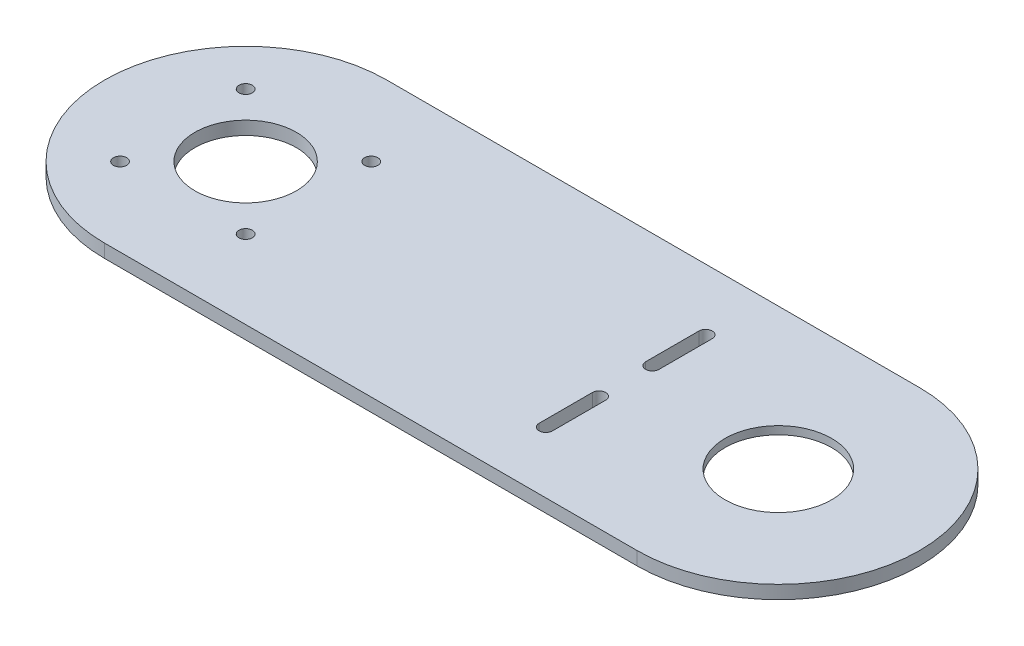
from build123d import *

# Parameters (mm, degrees)
BOSS_EXTRUDE1_DEPTH = 5
SKETCH2_R           = 20
CUT_EXTRUDE1_DEPTH  = 6
SKETCH3_R           = 30
CUT_EXTRUDE2_DEPTH  = 2
SKETCH4_R           = 2.5
SKETCH4_R_2         = 19.05
CUT_EXTRUDE3_DEPTH  = 6


with BuildPart() as part:
    # Sketch1 → Boss-Extrude1 (new body)
    with BuildSketch(Plane(origin=(0, 0, 0), x_dir=(1, 0, 0), z_dir=(0, 1, 0))):
        with BuildLine():
            ThreePointArc((-100, 53), (-153, 0), (-100, -53))
            Line((-100, -53), (-100, 53))
        make_face()
        with BuildLine():
            Line((-100, 53), (-100, -53))
            ThreePointArc((-100, -53), (-62.523340597, -37.476659403), (-47, 0))
            ThreePointArc((-47, 0), (-62.523340597, 37.476659403), (-100, 53))
        make_face()
        with BuildLine():
            ThreePointArc((-47, 0), (-62.523340597, -37.476659403), (-100, -53))
            Line((-100, -53), (100, -53))
            ThreePointArc((100, -53), (47, 0), (100, 53))
            Line((100, 53), (-100, 53))
            ThreePointArc((-100, 53), (-62.523340597, 37.476659403), (-47, 0))
        make_face()
        with BuildLine():
            ThreePointArc((100, 53), (47, 0), (100, -53))
            Line((100, -53), (100, 53))
        make_face()
        with BuildLine():
            Line((100, 53), (100, -53))
            ThreePointArc((100, -53), (137.476659403, -37.476659403), (153, 0))
            ThreePointArc((153, 0), (137.476659403, 37.476659403), (100, 53))
        make_face()
    extrude(amount=BOSS_EXTRUDE1_DEPTH)

    # Sketch2 → Cut-Extrude1 (cut, through all)
    with BuildSketch(Plane(origin=(0, 5, 0), x_dir=(1, 0, 0), z_dir=(0, 1, 0))):
        with Locations((100, 0)):
            Circle(SKETCH2_R)
    extrude(amount=-CUT_EXTRUDE1_DEPTH, mode=Mode.SUBTRACT)

    # Sketch3 → Cut-Extrude2 (cut)
    with BuildSketch(Plane.XZ):
        with Locations((100, 0)):
            Circle(SKETCH3_R)
    extrude(amount=-CUT_EXTRUDE2_DEPTH, mode=Mode.SUBTRACT)

    # Sketch4 → Cut-Extrude3 (cut, through all)
    with BuildSketch(Plane(origin=(0, 5, 0), x_dir=(1, 0, 0), z_dir=(0, 1, 0))):
        with Locations((-123.57, 23.57)):
            Circle(SKETCH4_R)
        with Locations((-76.43, 23.57)):
            Circle(SKETCH4_R)
        with Locations((-76.43, -23.57)):
            Circle(SKETCH4_R)
        with Locations((-123.57, -23.57)):
            Circle(SKETCH4_R)
        with Locations((-100, 0)):
            Circle(SKETCH4_R_2)
        with BuildLine():
            Line((45.182638641, 10), (45.182638641, 30))
            ThreePointArc((45.182638641, 30), (42.682638641, 32.5), (40.182638641, 30))
            Line((40.182638641, 30), (40.182638641, 10))
            ThreePointArc((40.182638641, 10), (42.682638641, 7.5), (45.182638641, 10))
        make_face()
        with BuildLine():
            Line((40.182638641, -10), (40.182638641, -30))
            ThreePointArc((40.182638641, -30), (42.682638641, -32.5), (45.182638641, -30))
            Line((45.182638641, -30), (45.182638641, -10))
            ThreePointArc((45.182638641, -10), (42.682638641, -7.5), (40.182638641, -10))
        make_face()
    extrude(amount=-CUT_EXTRUDE3_DEPTH, mode=Mode.SUBTRACT)


solid = part.part
